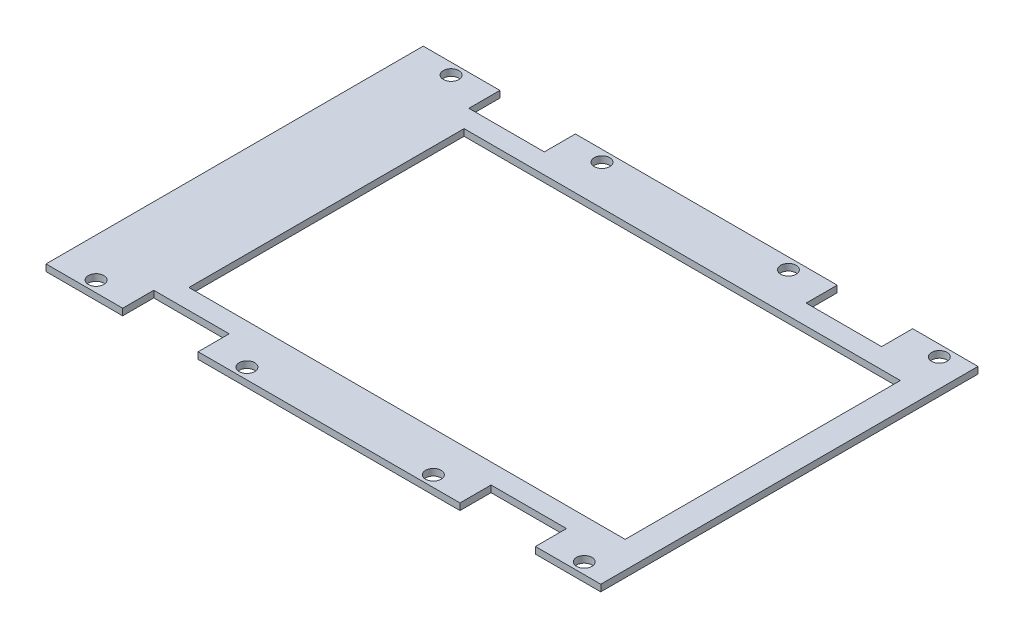
from build123d import *

# Parameters (mm, degrees)
SKETCH_1_W          = 125
SKETCH_1_H          = 85
EXTRUDE_1_DEPTH     = 1.5
SKETCH_2_W          = 98.3
SKETCH_2_H          = 62
CUT_EXTRUDE_1_DEPTH = 1.5
SKETCH_4_R          = 1.75
CUT_EXTRUDE_2_DEPTH = 10
SKETCH_5_R          = 1.75
CUT_EXTRUDE_3_DEPTH = 10
SKETCH_6_W          = 17
SKETCH_6_H          = 9
CUT_EXTRUDE_4_DEPTH = 10


with BuildPart() as part:
    # 스케치1 → 보스-돌출1 (new body)
    with BuildSketch(Plane(origin=(0, 0, 0), x_dir=(1, 0, 0), z_dir=(0, 1, 0))):
        with Locations((-7.35, 0)):
            Rectangle(SKETCH_1_W, SKETCH_1_H)
    extrude(amount=EXTRUDE_1_DEPTH)

    # 스케치2 → 컷-돌출1 (cut)
    with BuildSketch(Plane(origin=(0, 1.5, 0), x_dir=(1, 0, 0), z_dir=(0, 1, 0))):
        Rectangle(SKETCH_2_W, SKETCH_2_H)
    extrude(amount=-CUT_EXTRUDE_1_DEPTH, mode=Mode.SUBTRACT)

    # 스케치4 → 컷-돌출2 (cut)
    with BuildSketch(Plane(origin=(0, 1.5, 0), x_dir=(1, 0, 0), z_dir=(0, 1, 0))):
        with Locations((-61.07, 40)):
            Circle(SKETCH_4_R)
        with Locations((48.93, 40)):
            Circle(SKETCH_4_R)
        with Locations((48.93, -40)):
            Circle(SKETCH_4_R)
        with Locations((-61.07, -40)):
            Circle(SKETCH_4_R)
    extrude(amount=-CUT_EXTRUDE_2_DEPTH, mode=Mode.SUBTRACT)

    # 스케치5 → 컷-돌출3 (cut)
    with BuildSketch(Plane(origin=(0, 1.5, 0), x_dir=(1, 0, 0), z_dir=(0, 1, 0))):
        with Locations((-27.07, -40)):
            Circle(SKETCH_5_R)
        with Locations((14.93, -40)):
            Circle(SKETCH_5_R)
        with Locations((-27.07, 40)):
            Circle(SKETCH_5_R)
        with Locations((14.93, 40)):
            Circle(SKETCH_5_R)
    extrude(amount=-CUT_EXTRUDE_3_DEPTH, mode=Mode.SUBTRACT)

    # 스케치6 → 컷-돌출4 (cut)
    with BuildSketch(Plane.XZ):
        with Locations((-44.07, 40)):
            Rectangle(SKETCH_6_W, SKETCH_6_H)
        with Locations((31.93, 40)):
            Rectangle(SKETCH_6_W, SKETCH_6_H)
        with Locations((-44.07, -40)):
            Rectangle(SKETCH_6_W, SKETCH_6_H)
        with Locations((31.93, -40)):
            Rectangle(SKETCH_6_W, SKETCH_6_H)
    extrude(amount=-CUT_EXTRUDE_4_DEPTH, mode=Mode.SUBTRACT)


solid = part.part
